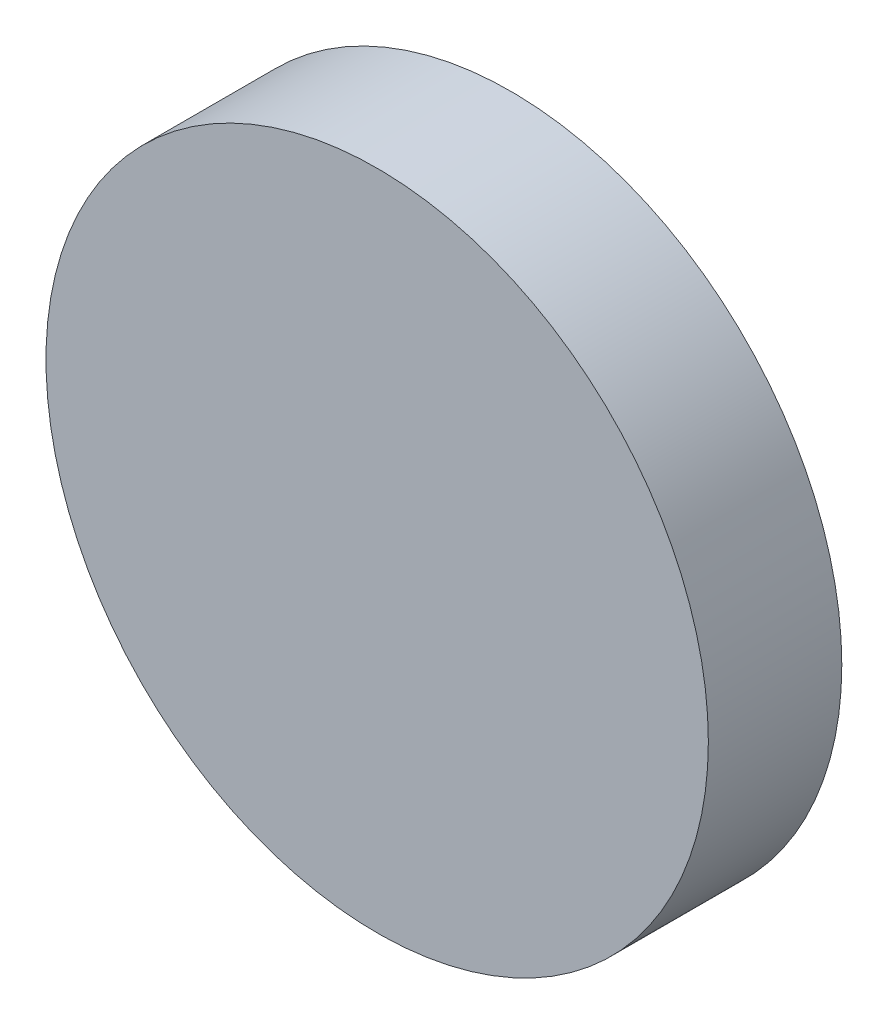
from build123d import *

# Parameters (mm, degrees)
SKETCH1_R           = 133.5
BOSS_EXTRUDE1_DEPTH = 53.8


with BuildPart() as part:
    # Sketch1 → Boss-Extrude1 (new body)
    with BuildSketch(Plane.XY):
        Circle(SKETCH1_R)
    extrude(amount=BOSS_EXTRUDE1_DEPTH)


solid = part.part
